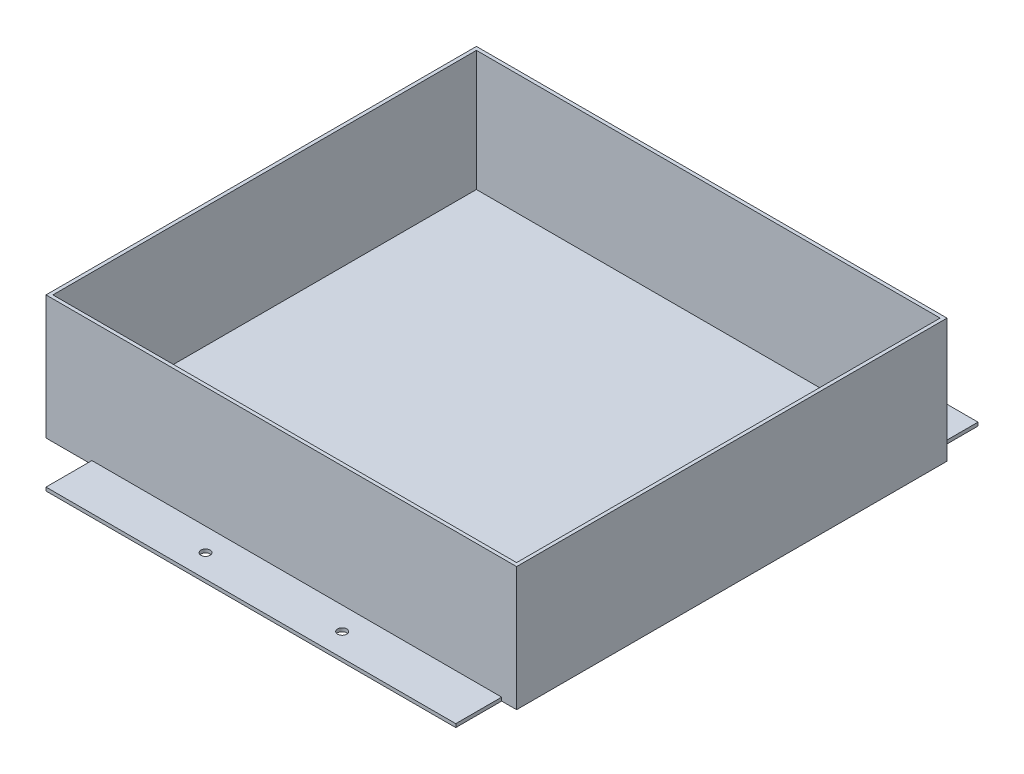
from build123d import *

# Parameters (mm, degrees)
SKETCH_1_R      = 4
EXTRUDE_2_DEPTH = 3
SKETCH_2_W      = 410
SKETCH_2_H      = 375
SKETCH_2_W_2    = 404
SKETCH_2_H_2    = 369
EXTRUDE_3_DEPTH = 105


with BuildPart() as part:
    # 草圖1 → 填料-伸長2 (new body)
    with BuildSketch(Plane(origin=(0, 0, 0), x_dir=(1, 0, 0), z_dir=(0, 1, 0))):
        Polygon((0, 0), (0, -375), (40, -375), (40, -415), (397, -415), (397, -375), (410, -375), (410, 0), (397, 0), (397, 40), (40, 40), (40, 0), align=None)
        with Locations((159, 20)):
            Circle(SKETCH_1_R, mode=Mode.SUBTRACT)
        with Locations((278, 20)):
            Circle(SKETCH_1_R, mode=Mode.SUBTRACT)
        with Locations((278, -395)):
            Circle(SKETCH_1_R, mode=Mode.SUBTRACT)
        with Locations((159, -395)):
            Circle(SKETCH_1_R, mode=Mode.SUBTRACT)
    extrude(amount=EXTRUDE_2_DEPTH)

    # 草圖2 → 填料-伸長3 (add)
    with BuildSketch(Plane(origin=(0, 3, 0), x_dir=(1, 0, 0), z_dir=(0, 1, 0))):
        with Locations((205, -187.5)):
            Rectangle(SKETCH_2_W, SKETCH_2_H)
        with Locations((205, -187.5)):
            Rectangle(SKETCH_2_W_2, SKETCH_2_H_2, mode=Mode.SUBTRACT)
    extrude(amount=EXTRUDE_3_DEPTH)


solid = part.part
